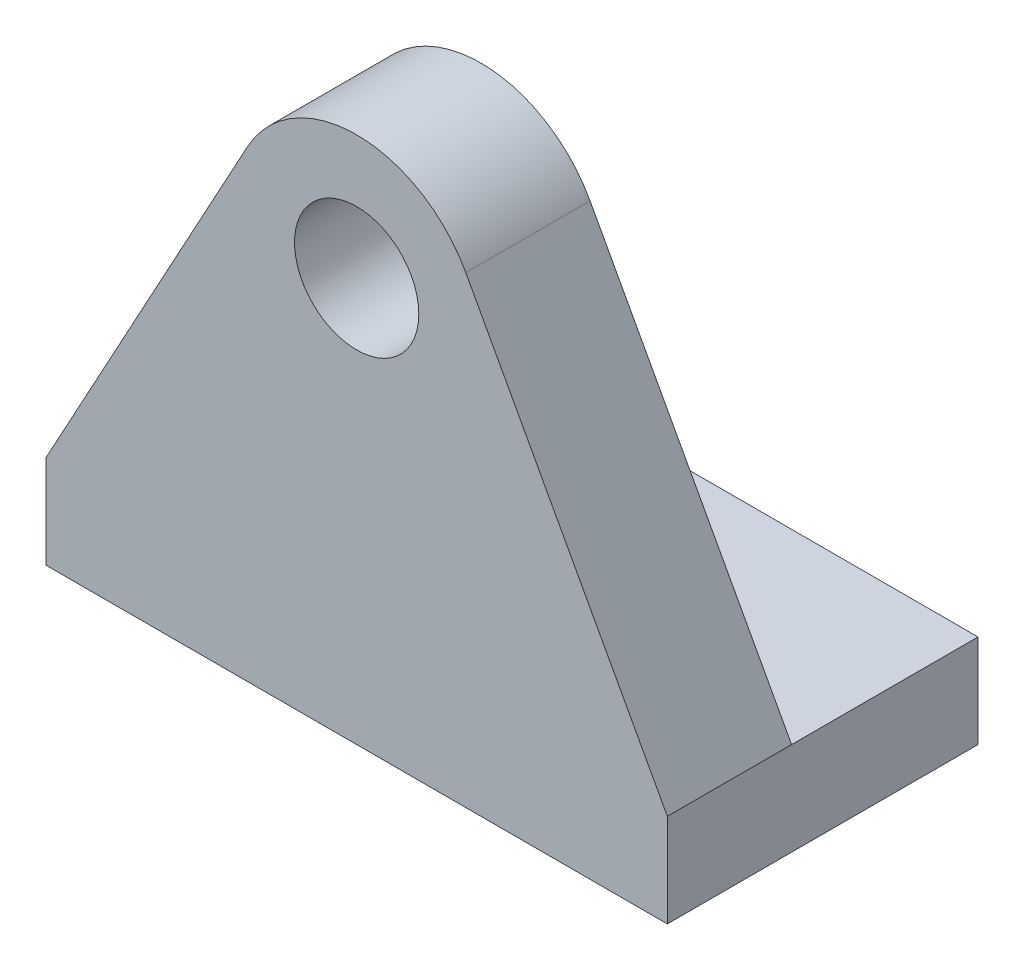
from build123d import *

# Parameters (mm, degrees)
SKETCH_1_R      = 2
EXTRUDE_1_DEPTH = 4
SKETCH_2_W      = 20
SKETCH_2_H      = 3
EXTRUDE_2_DEPTH = 10


with BuildPart() as part:
    # 草图1 → 凸台-拉伸1 (new body)
    with BuildSketch(Plane.XY):
        with BuildLine():
            Line((-10, -10), (10, -10))
            Line((10, -10), (3.512931993, 1.912931993))
            ThreePointArc((3.512931993, 1.912931993), (0, 4), (-3.512931993, 1.912931993))
            Line((-3.512931993, 1.912931993), (-10, -10))
        make_face()
        Circle(SKETCH_1_R, mode=Mode.SUBTRACT)
    extrude(amount=EXTRUDE_1_DEPTH)

    # 草图2 → 凸台-拉伸2 (add)
    with BuildSketch(Plane.XY.offset(4)):
        with Locations((0, -11.5)):
            Rectangle(SKETCH_2_W, SKETCH_2_H)
    extrude(amount=-EXTRUDE_2_DEPTH)


solid = part.part
